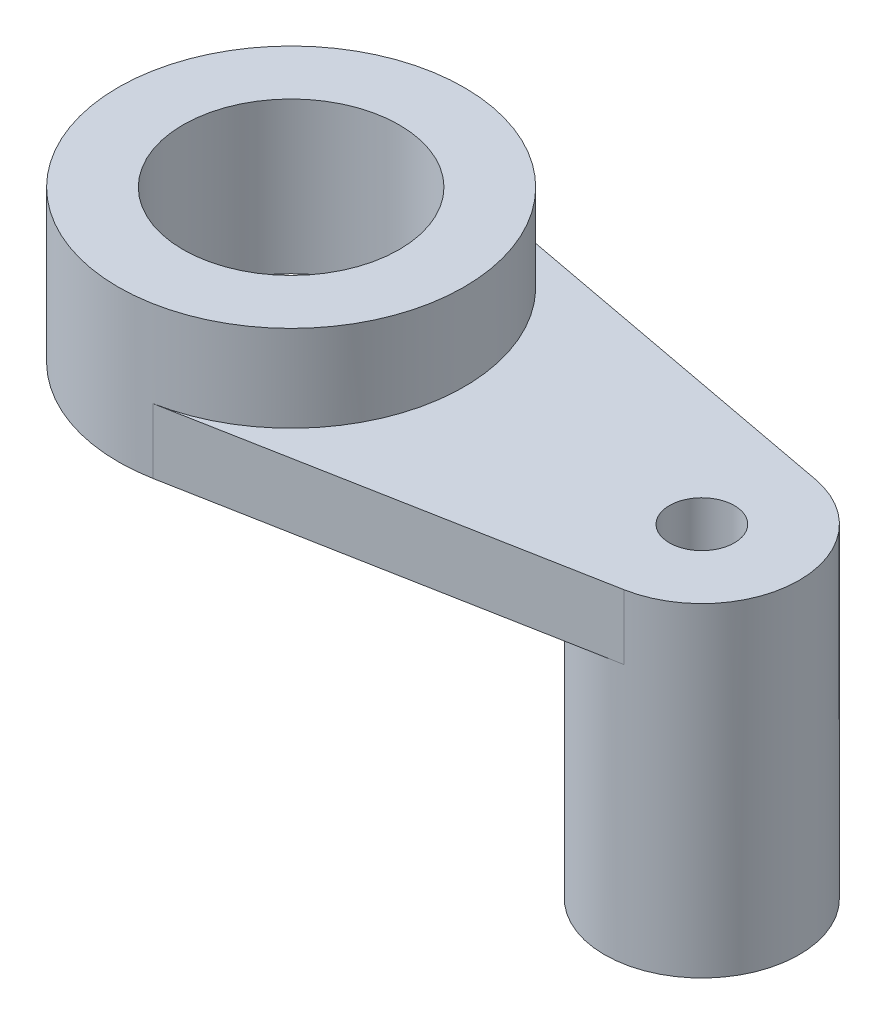
from build123d import *

# Parameters (mm, degrees)
SKETCH1_R           = 16
SKETCH1_R_2         = 10
SKETCH1_R_3         = 9
SKETCH1_R_4         = 3
BOSS_EXTRUDE1_DEPTH = 6
SKETCH1_3_R         = 16
SKETCH1_3_R_2       = 10
BOSS_EXTRUDE2_DEPTH = 14
SKETCH1_5_R         = 9
SKETCH1_5_R_2       = 3
BOSS_EXTRUDE3_DEPTH = 24


with BuildPart() as part:
    # Sketch1 → Boss-Extrude1 (new body)
    with BuildSketch(Plane(origin=(0, 0, 0), x_dir=(1, 0, 0), z_dir=(0, 1, 0))):
        Circle(SKETCH1_R)
        with Locations(Location((0, 0, 0), (0, 0, 270))):
            Circle(SKETCH1_R_2, mode=Mode.SUBTRACT)
        with BuildLine():
            Line((39.657894737, 8.845981293), (2.947368421, 15.726188966))
            ThreePointArc((2.947368421, 15.726188966), (12.311740225, 10.218661979), (16, 0))
            ThreePointArc((16, 0), (12.311740225, -10.218661979), (2.947368421, -15.726188966))
            Line((2.947368421, -15.726188966), (39.657894737, -8.845981293))
            ThreePointArc((39.657894737, -8.845981293), (29, 0), (39.657894737, 8.845981293))
        make_face()
        with Locations((38, 0)):
            Circle(SKETCH1_R_3)
        with Locations(Location((38, 0, 0), (0, 0, 270))):
            Circle(SKETCH1_R_4, mode=Mode.SUBTRACT)
    extrude(amount=BOSS_EXTRUDE1_DEPTH)

    # Sketch1_3 → Boss-Extrude2 (add)
    with BuildSketch(Plane(origin=(0, 0, 0), x_dir=(1, 0, 0), z_dir=(0, 1, 0))):
        with Locations(Location((0, 0, 0), (0, 0, 79.384892149))):
            Circle(SKETCH1_3_R)
        with Locations(Location((0, 0, 0), (0, 0, 270))):
            Circle(SKETCH1_3_R_2, mode=Mode.SUBTRACT)
    extrude(amount=BOSS_EXTRUDE2_DEPTH)

    # Sketch1_5 → Boss-Extrude3 (add)
    with BuildSketch(Plane(origin=(0, 0, 0), x_dir=(1, 0, 0), z_dir=(0, 1, 0))):
        with Locations(Location((38, 0, 0), (0, 0, 79.384892149))):
            Circle(SKETCH1_5_R)
        with Locations(Location((38, 0, 0), (0, 0, 270))):
            Circle(SKETCH1_5_R_2, mode=Mode.SUBTRACT)
    extrude(amount=-BOSS_EXTRUDE3_DEPTH)


solid = part.part
